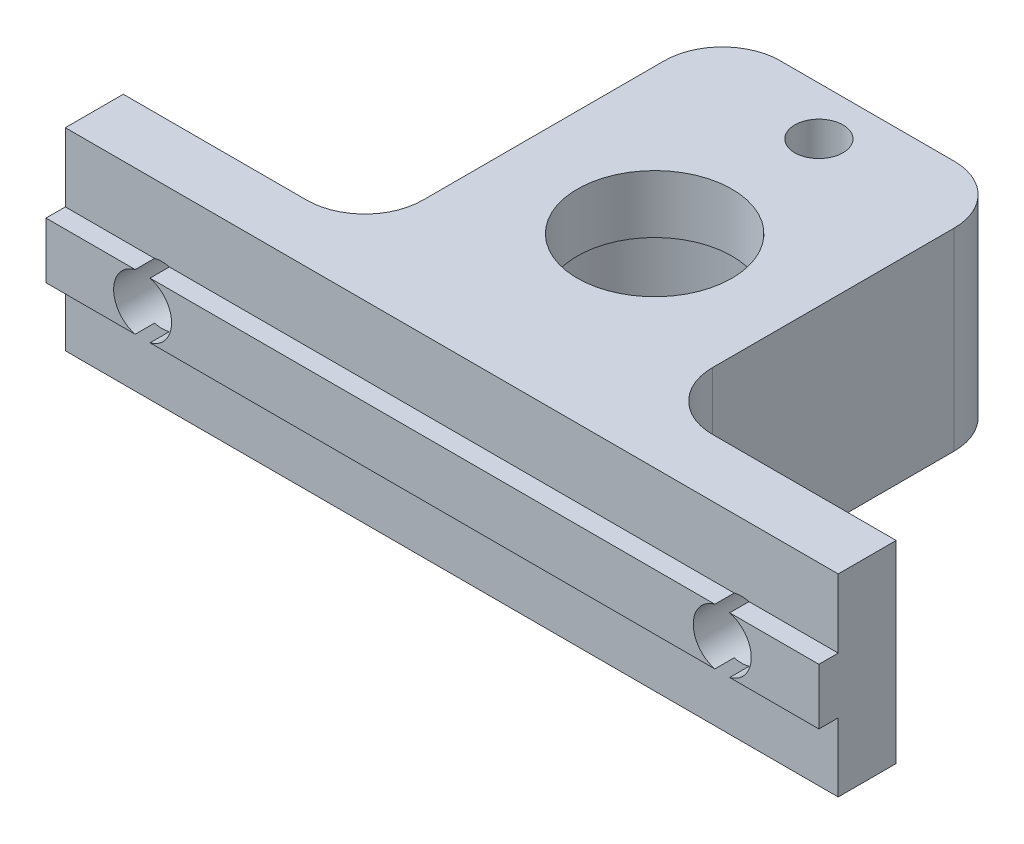
from build123d import *

# Parameters (mm, degrees)
ESQUISSE1_W               = 40
ESQUISSE1_H               = 10
MAIN_DEPTH                = 3
ESQUISSE2_W               = 40
ESQUISSE2_H               = 2.9
MAKERBEAMRAIL_DEPTH       = 1
ESQUISSE3_R               = 1.5
MAKERBEAMHOLE_DEPTH       = 5
MAKERBEAMHOLEREPEAT_COUNT = 2
MAKERBEAMHOLEREPEAT_PITCH = 30
SKETCH3_W                 = 15
SKETCH3_H                 = 18.5
MAGNETSUPPORT_DEPTH       = 10
FILLET5_R                 = 3
SKETCH4_R                 = 6.2
MAGNETBIGHOLE_DEPTH       = 7
SKETCH5_R                 = 4
MAGNETSMALLHOLE_DEPTH     = 4
SKETCH6_R                 = 1.25
SUBMAGNETFIXHOLE_DEPTH    = 11


with BuildPart() as part:
    # Esquisse1 → Main (new body)
    with BuildSketch(Plane.XY):
        with Locations((0, 5)):
            Rectangle(ESQUISSE1_W, ESQUISSE1_H)
    extrude(amount=MAIN_DEPTH)

    # Esquisse2 → MakerBeamRail (add)
    with BuildSketch(Plane.XY.offset(3)):
        with Locations((0, 5)):
            Rectangle(ESQUISSE2_W, ESQUISSE2_H)
    extrude(amount=MAKERBEAMRAIL_DEPTH)

    # Esquisse3 → MakerBeamHole (cut, through all)
    with BuildSketch(Plane(origin=(0, 0, 0), x_dir=(-1, 0, 0), z_dir=(0, 0, -1))):
        with Locations((-15, 5)):
            Circle(ESQUISSE3_R)
    makerbeamhole = extrude(amount=-MAKERBEAMHOLE_DEPTH, mode=Mode.SUBTRACT)

    # MakerBeamHoleRepeat: MakerBeamHole ×2
    with Locations(*[(-i * MAKERBEAMHOLEREPEAT_PITCH, 0, 0) for i in range(1, MAKERBEAMHOLEREPEAT_COUNT)]):
        add(makerbeamhole, mode=Mode.SUBTRACT)

    # Sketch3 → MagnetSupport (add)
    with BuildSketch(Plane(origin=(0, 0, 0), x_dir=(1, 0, 0), z_dir=(0, 1, 0))):
        with Locations((0, 9.25)):
            Rectangle(SKETCH3_W, SKETCH3_H)
    extrude(amount=MAGNETSUPPORT_DEPTH)

    # Fillet5
    fillet5_edges = [part.edges().sort_by_distance(p)[0] for p in [
        (-7.5, 5, -18.5),
        (-7.5, 5, 0),
        (7.5, 5, 0),
        (7.5, 5, -18.5),
    ]]
    fillet(fillet5_edges, radius=FILLET5_R)

    # Sketch4 → MagnetBigHole (cut)
    with BuildSketch(Plane.XZ):
        with Locations((0, -7.5)):
            Circle(SKETCH4_R)
    extrude(amount=-MAGNETBIGHOLE_DEPTH, mode=Mode.SUBTRACT)

    # Sketch5 → MagnetSmallHole (cut, through all)
    with BuildSketch(Plane.XZ.offset(-7)):
        with Locations((0, -7.5)):
            Circle(SKETCH5_R)
    extrude(amount=-MAGNETSMALLHOLE_DEPTH, mode=Mode.SUBTRACT)

    # Sketch6 → SubMagnetFixHole (cut, through all)
    with BuildSketch(Plane(origin=(0, 10, 0), x_dir=(1, 0, 0), z_dir=(0, 1, 0))):
        with Locations((0, 16)):
            Circle(SKETCH6_R)
    extrude(amount=-SUBMAGNETFIXHOLE_DEPTH, mode=Mode.SUBTRACT)


solid = part.part
